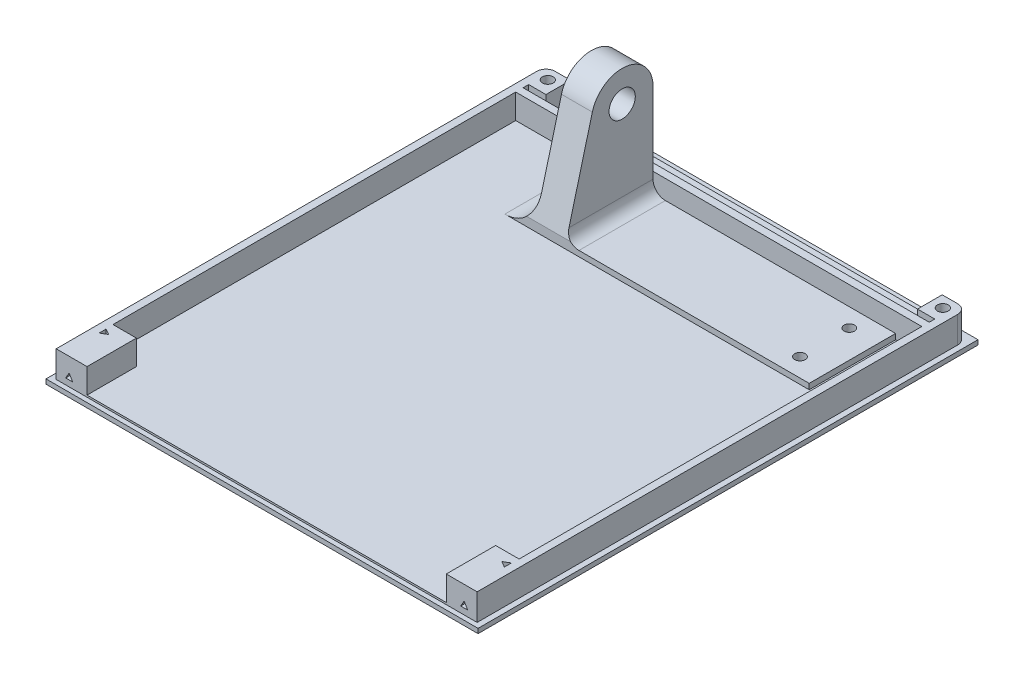
from build123d import *

# Parameters (mm, degrees)
SALIENTE_EXTRUIR1_DEPTH = 28
CROQUIS2_R              = 4.25
CORTAR_EXTRUIR1_DEPTH   = 89.6
CROQUIS5_W              = 140
CROQUIS5_H              = 162
PLACA_BASE_DEPTH        = 2.1
REDONDEO4_R             = 10
REDONDEO5_R             = 4
CROQUIS6_OUTSIDE_W      = 185.718
CROQUIS6_OUTSIDE_H      = 207.718
CROQUIS6_OUTSIDE_W_2    = 136.4
CROQUIS6_OUTSIDE_H_2    = 158.7
CORTAR_EXTRUIR3_DEPTH   = 0.6
SALIENTE_EXTRUIR2_DEPTH = 8
TORNILLOS_BAE_DEPTH     = 14
CROQUIS10_R             = 1.75
CORTAR_EXTRUIR6_DEPTH   = 10.1
MOT_SOP_NEMA_REACH      = 46
CROQUIS3_R              = 1.7
CORTAR_EXTRUIR7_START   = -10.1
CORTAR_EXTRUIR7_DEPTH   = 10.1
REDONDEO3_R             = 3


with BuildPart() as part:
    # Croquis1 → Saliente-Extruir1 (new body)
    with BuildSketch(Plane.XY):
        Polygon((63.3, 3.9), (-15.3, 3.9), (-15.3, 44), (-25.3, 44), (-25.3, 0), (63.3, 0), align=None)
    extrude(amount=SALIENTE_EXTRUIR1_DEPTH)

    # Croquis2 → Cortar-Extruir1 (cut, through all)
    with BuildSketch(Plane.ZY.offset(25.3)):
        with Locations((10, 34)):
            Circle(CROQUIS2_R)
        with BuildLine():
            Line((28, 5), (19.66863343, 36.552944888))
            ThreePointArc((19.66863343, 36.552944888), (8.712819806, 43.916812348), (0, 34))
            Line((0, 34), (0, 33))
            Line((0, 33), (-1, 33))
            Line((-1, 33), (-1, 45))
            Line((-1, 45), (29, 45))
            Line((29, 45), (29, 5))
            Line((29, 5), (28, 5))
        make_face()
    extrude(amount=-CORTAR_EXTRUIR1_DEPTH, mode=Mode.SUBTRACT)

    # Croquis5 → PLACA-BASE (add)
    with BuildSketch(Plane(origin=(0, 0, 0), x_dir=(1, 0, 0), z_dir=(0, 1, 0))):
        with Locations((6, -67)):
            Rectangle(CROQUIS5_W, CROQUIS5_H)
    extrude(amount=PLACA_BASE_DEPTH)

    # Redondeo4
    redondeo4_edges = [part.edges().sort_by_distance(p)[0] for p in [
        (-25.3, 2.1, 14),
    ]]
    fillet(redondeo4_edges, radius=REDONDEO4_R)

    # Redondeo5
    redondeo5_edges = [part.edges().sort_by_distance(p)[0] for p in [
        (-15.3, 3.9, 14),
    ]]
    fillet(redondeo5_edges, radius=REDONDEO5_R)

    # Croquis6 outside → Cortar-Extruir3 (cut)
    with BuildSketch(Plane(origin=(0, 2.1, 0), x_dir=(1, 0, 0), z_dir=(0, 1, 0))):
        with Locations((6, -67)):
            Rectangle(CROQUIS6_OUTSIDE_W, CROQUIS6_OUTSIDE_H)
        with Locations((6, -67.15)):
            Rectangle(CROQUIS6_OUTSIDE_W_2, CROQUIS6_OUTSIDE_H_2, mode=Mode.SUBTRACT)
    extrude(amount=-CORTAR_EXTRUIR3_DEPTH, mode=Mode.SUBTRACT)

    # Croquis8 → Saliente-Extruir2 (add)
    with BuildSketch(Plane(origin=(0, 2.1, 0), x_dir=(1, 0, 0), z_dir=(0, 1, 0))):
        Polygon((66.2, 12.2), (74.2, 12.2), (74.2, -146.5), (64.2, -146.5), (64.2, -130.5), (71.8, -130.5), (71.8, 0), (6, 0), (6, 2.4), (71.8, 2.4), (71.8, 4.2), (66.2, 4.2), align=None)
    saliente_extruir2 = extrude(amount=SALIENTE_EXTRUIR2_DEPTH)

    # Croquis9 → TORNILLOS-BAE (cut)
    with BuildSketch(Plane.XY.offset(146.5)):
        Polygon((70, 5.4), (68.874166975, 3.45), (71.125833025, 3.45), align=None)
    tornillos_bae = extrude(amount=-TORNILLOS_BAE_DEPTH, mode=Mode.SUBTRACT)

    # Croquis10 → Cortar-Extruir6 (cut)
    with BuildSketch(Plane(origin=(0, 10.1, 0), x_dir=(1, 0, 0), z_dir=(0, 1, 0))):
        with Locations((70, 8.6)):
            Circle(CROQUIS10_R)
    cortar_extruir6 = extrude(amount=-CORTAR_EXTRUIR6_DEPTH, mode=Mode.SUBTRACT)

    # Croquis3 → MOT-SOP-NEMA (cut, up to next)
    with BuildSketch(Plane.XZ, mode=Mode.PRIVATE) as mot_sop_nema_sk1:
        with Locations((54.3, 22)):
            Circle(CROQUIS3_R)
    mot_sop_nema_tool1 = extrude(mot_sop_nema_sk1.sketch, amount=-MOT_SOP_NEMA_REACH, mode=Mode.PRIVATE) & part.part
    add(mot_sop_nema_tool1.solids().sort_by_distance((54.3, 0, 22))[0], mode=Mode.SUBTRACT)
    # Croquis3 → MOT-SOP-NEMA (cut, up to next)
    with BuildSketch(Plane.XZ, mode=Mode.PRIVATE) as mot_sop_nema_sk2:
        with Locations((54.3, 6)):
            Circle(CROQUIS3_R)
    mot_sop_nema_tool2 = extrude(mot_sop_nema_sk2.sketch, amount=-MOT_SOP_NEMA_REACH, mode=Mode.PRIVATE) & part.part
    add(mot_sop_nema_tool2.solids().sort_by_distance((54.3, 0, 6))[0], mode=Mode.SUBTRACT)

    # Croquis11 → Cortar-Extruir7 (cut)
    with BuildSketch(Plane(origin=(0, 10.1, 0), x_dir=(1, 0, 0), z_dir=(0, 1, 0)).offset(CORTAR_EXTRUIR7_START)):
        Polygon((69.7, -134), (71.65, -135.125833025), (71.65, -132.874166975), align=None)
    cortar_extruir7 = extrude(amount=CORTAR_EXTRUIR7_DEPTH, mode=Mode.SUBTRACT)

    # Simetría3: Saliente-Extruir2, TORNILLOS-BAE, Cortar-Extruir6, Cortar-Extruir7 across plane
    add(saliente_extruir2.mirror(Plane.ZY.offset(-6)))
    add(tornillos_bae.mirror(Plane.ZY.offset(-6)), mode=Mode.SUBTRACT)
    add(cortar_extruir6.mirror(Plane.ZY.offset(-6)), mode=Mode.SUBTRACT)
    add(cortar_extruir7.mirror(Plane.ZY.offset(-6)), mode=Mode.SUBTRACT)

    # Redondeo3
    redondeo3_edges = [part.edges().sort_by_distance(p)[0] for p in [
        (-62.2, 5.8, -12.2),
        (74.2, 5.8, -12.2),
    ]]
    fillet(redondeo3_edges, radius=REDONDEO3_R)


solid = part.part
